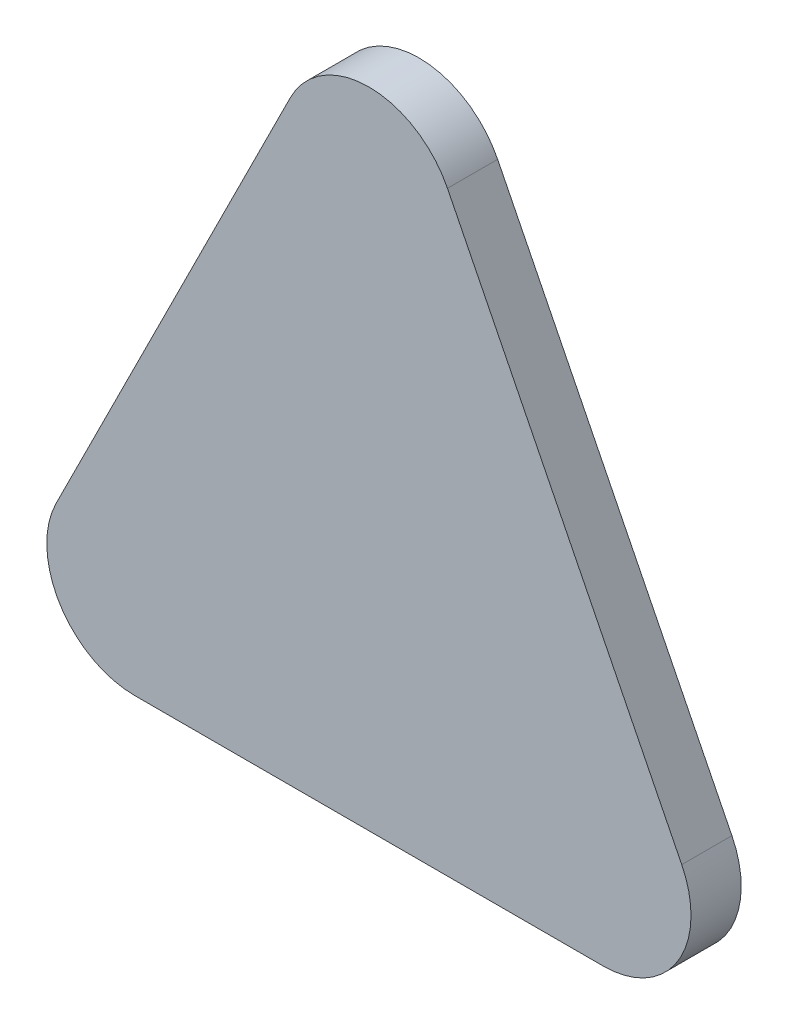
from build123d import *

# Parameters (mm, degrees)
BOSS_EXTRUDE1_DEPTH = 5.08


with BuildPart() as part:
    # Sketch1 → Boss-Extrude1 (new body)
    with BuildSketch(Plane.XY):
        with BuildLine():
            Line((7.951457728, 60.297084544), (31.667135568, 12.865728864))
            ThreePointArc((31.667135568, 12.865728864), (31.277963526, 4.216250413), (23.71567784, 0))
            Line((23.71567784, 0), (-23.71567784, 0))
            ThreePointArc((-23.71567784, 0), (-31.277963526, 4.216250413), (-31.667135568, 12.865728864))
            Line((-31.667135568, 12.865728864), (-7.951457728, 60.297084544))
            ThreePointArc((-7.951457728, 60.297084544), (0, 65.21135568), (7.951457728, 60.297084544))
        make_face()
    extrude(amount=BOSS_EXTRUDE1_DEPTH)


solid = part.part
